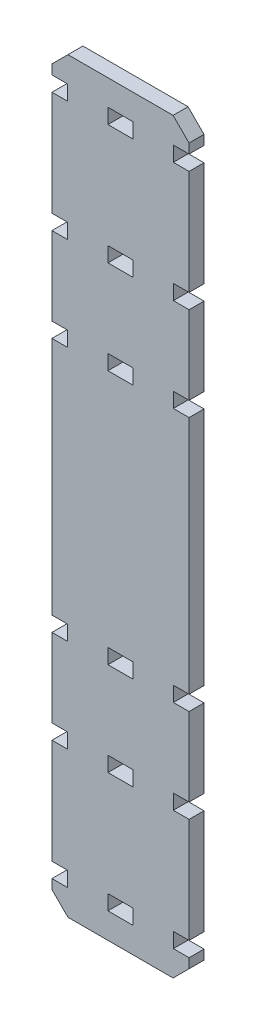
from build123d import *

# Parameters (mm, degrees)
SKETCH1_W           = 8
SKETCH1_H           = 4.7625
BOSS_EXTRUDE1_DEPTH = 4.7625
CHAMFER1_SIZE       = 5.08


with BuildPart() as part:
    # Sketch1 → Boss-Extrude1 (new body)
    with BuildSketch(Plane.XY):
        Polygon((43.598645263, 118.7905), (0, 118.7905), (0, 110.6625), (5, 110.6625), (5, 105.9), (0, 105.9), (0, 72.5625), (5, 72.5625), (5, 67.8), (0, 67.8), (0, 42.8625), (5, 42.8625), (5, 38.1), (0, 38.1), (0, -38.1), (5, -38.1), (5, -42.8625), (0, -42.8625), (0, -67.8), (5, -67.8), (5, -72.5625), (0, -72.5625), (0, -105.9), (5, -105.9), (5, -110.6625), (0, -110.6625), (0, -118.7905), (43.598645263, -118.7905), (43.598645263, -110.6625), (38.598645263, -110.6625), (38.598645263, -105.9), (43.598645263, -105.9), (43.598645263, -72.5625), (38.598645263, -72.5625), (38.598645263, -67.8), (43.598645263, -67.8), (43.598645263, -42.8625), (38.598645263, -42.8625), (38.598645263, -38.1), (43.598645263, -38.1), (43.598645263, 38.1), (38.598645263, 38.1), (38.598645263, 42.8625), (43.598645263, 42.8625), (43.598645263, 67.8), (38.598645263, 67.8), (38.598645263, 72.5625), (43.598645263, 72.5625), (43.598645263, 105.9), (38.598645263, 105.9), (38.598645263, 110.6625), (43.598645263, 110.6625), align=None)
        with Locations((21.799322631, 108.28125)):
            Rectangle(SKETCH1_W, SKETCH1_H, mode=Mode.SUBTRACT)
        with Locations((21.799322631, 70.18125)):
            Rectangle(SKETCH1_W, SKETCH1_H, mode=Mode.SUBTRACT)
        with Locations((21.799322631, 40.48125)):
            Rectangle(SKETCH1_W, SKETCH1_H, mode=Mode.SUBTRACT)
        with Locations((21.799322631, -40.48125)):
            Rectangle(SKETCH1_W, SKETCH1_H, mode=Mode.SUBTRACT)
        with Locations((21.799322631, -70.18125)):
            Rectangle(SKETCH1_W, SKETCH1_H, mode=Mode.SUBTRACT)
        with Locations((21.799322631, -108.28125)):
            Rectangle(SKETCH1_W, SKETCH1_H, mode=Mode.SUBTRACT)
    extrude(amount=BOSS_EXTRUDE1_DEPTH)

    # Chamfer1
    chamfer1_edges = [part.edges().sort_by_distance(p)[0] for p in [
        (43.598645263, 118.7905, 2.38125),
        (0, 118.7905, 2.38125),
        (43.598645263, -118.7905, 2.38125),
        (0, -118.7905, 2.38125),
    ]]
    chamfer(chamfer1_edges, length=CHAMFER1_SIZE)


solid = part.part
